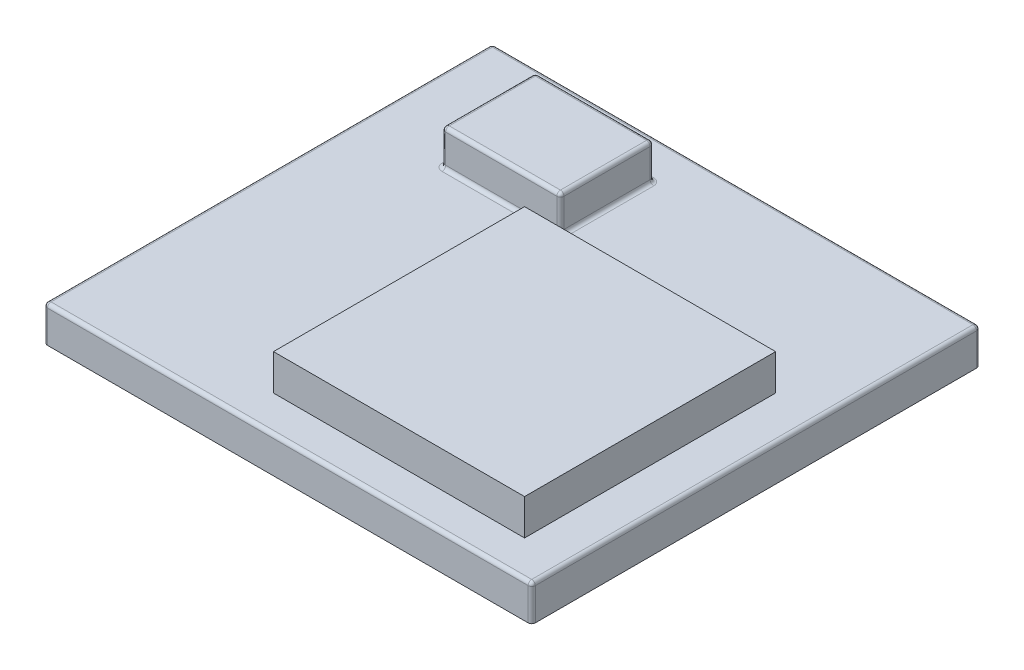
from build123d import *

# Parameters (mm, degrees)
SKETCH1_W           = 13.6
SKETCH1_H           = 12.5
BOSS_EXTRUDE1_DEPTH = 1
SKETCH2_W           = 7
SKETCH2_H           = 7
BOSS_EXTRUDE2_DEPTH = 1
SKETCH3_W           = 3.3
SKETCH3_H           = 2.6
BOSS_EXTRUDE3_DEPTH = 1
FILLET1_R           = 0.1


with BuildPart() as part:
    # Sketch1 → Boss-Extrude1 (new body)
    with BuildSketch(Plane(origin=(0, 0, 0), x_dir=(1, 0, 0), z_dir=(0, 1, 0))):
        Rectangle(SKETCH1_W, SKETCH1_H)
    extrude(amount=BOSS_EXTRUDE1_DEPTH)

    # Sketch2 → Boss-Extrude2 (add)
    with BuildSketch(Plane(origin=(0, 1, 0), x_dir=(1, 0, 0), z_dir=(0, 1, 0))):
        with Locations((2.1, -1.75)):
            Rectangle(SKETCH2_W, SKETCH2_H)
    extrude(amount=BOSS_EXTRUDE2_DEPTH)

    # Sketch3 → Boss-Extrude3 (add)
    with BuildSketch(Plane(origin=(0, 1, 0), x_dir=(1, 0, 0), z_dir=(0, 1, 0))):
        with Locations((-2.85, 3.85)):
            Rectangle(SKETCH3_W, SKETCH3_H)
    extrude(amount=BOSS_EXTRUDE3_DEPTH)

    # Fillet1
    fillet1_edges = [part.edges().sort_by_distance(p)[0] for p in [
        (6.8, 1, 0),
        (0, 1, -6.25),
        (-4.5, 1, -3.85),
        (-4.5, 1.5, -5.15),
        (-2.85, 1, -2.55),
        (-4.5, 1.5, -2.55),
        (-1.2, 1, -3.85),
        (-1.2, 1.5, -2.55),
        (-2.85, 1, -5.15),
        (-1.2, 1.5, -5.15),
        (-4.5, 2, -3.85),
        (-2.85, 2, -2.55),
        (-1.2, 2, -3.85),
        (-2.85, 2, -5.15),
        (-6.8, 1, 0),
        (0, 1, 6.25),
        (-6.8, 0.5, -6.25),
        (6.8, 0.5, -6.25),
        (6.8, 0.5, 6.25),
        (-6.8, 0.5, 6.25),
    ]]
    fillet(fillet1_edges, radius=FILLET1_R)


solid = part.part
